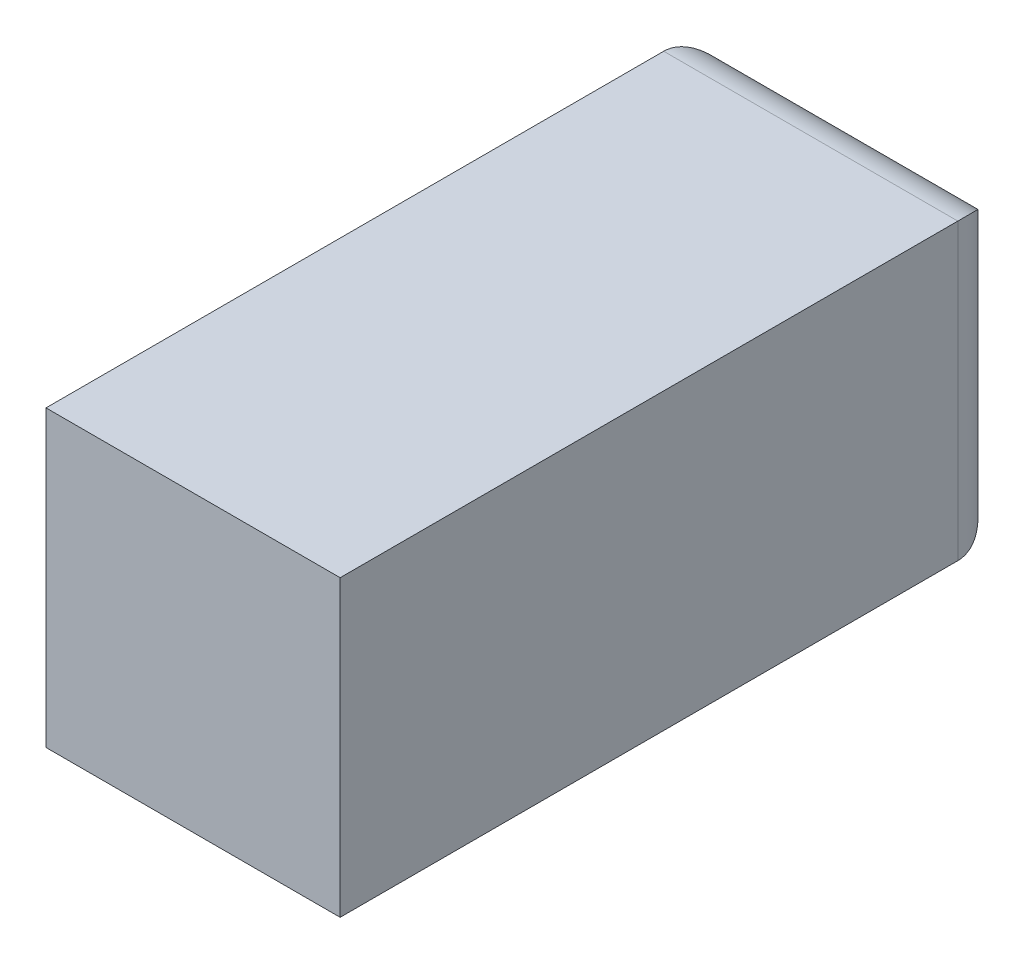
from build123d import *

# Parameters (mm, degrees)
SKETCH1_W           = 15
SKETCH1_H           = 15
BOSS_EXTRUDE1_DEPTH = 34
FILLET2_R           = 2.5


with BuildPart() as part:
    # Sketch1 → Boss-Extrude1 (new body)
    with BuildSketch(Plane.XY):
        with Locations((7.5, 7.5)):
            Rectangle(SKETCH1_W, SKETCH1_H)
    extrude(amount=BOSS_EXTRUDE1_DEPTH)

    # Fillet2
    fillet2_edges = [part.edges().sort_by_distance(p)[0] for p in [
        (7.5, 15, 0),
        (15, 7.5, 0),
        (7.5, 0, 0),
        (0, 7.5, 0),
    ]]
    fillet(fillet2_edges, radius=FILLET2_R)


solid = part.part
